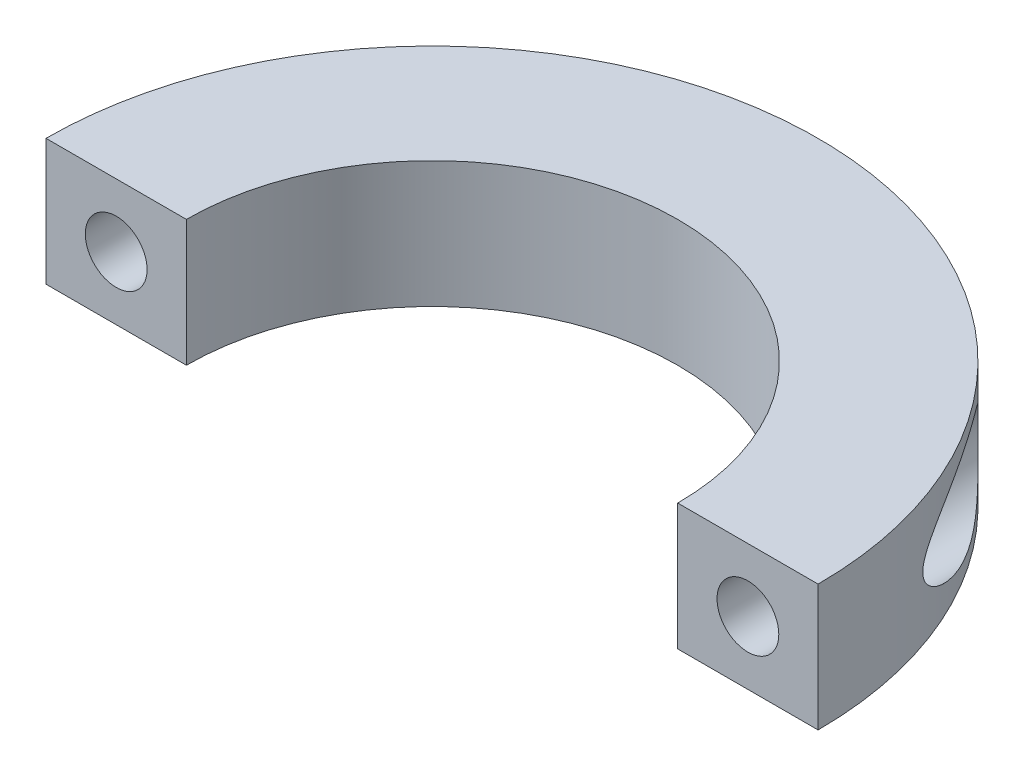
from build123d import *

# Parameters (mm, degrees)
BOSS_EXTRUDE1_DEPTH        = 4.5
BOSS_EXTRUDE1_DEPTH_BACK   = 4.5
F_4_4_4_4_DIAMETER_HOLE1_D = 4.4
CUT_EXTRUDE1_START         = -8
SKETCH7_R                  = 3.5
CUT_EXTRUDE1_DEPTH         = 18


with BuildPart() as part:
    # Sketch1 → Boss-Extrude1 (new, two sides: drawn at the far end of the back side and taken through both)
    with BuildSketch(Plane(origin=(0, 0, 0), x_dir=(1, 0, 0), z_dir=(0, 1, 0)).offset(-BOSS_EXTRUDE1_DEPTH_BACK)):
        with BuildLine():
            Line((-27.5, 0), (-17.5, 0))
            ThreePointArc((-17.5, 0), (0, 17.5), (17.5, 0))
            Line((17.5, 0), (27.5, 0))
            ThreePointArc((27.5, 0), (0, 27.5), (-27.5, 0))
        make_face()
    extrude(amount=BOSS_EXTRUDE1_DEPTH + BOSS_EXTRUDE1_DEPTH_BACK)

    # Ø4.4 (4.4) Diameter Hole1 (through all)
    with Locations(Plane(origin=(22.5, 0, 0), x_dir=(1, 0, 0), z_dir=(0, 0, 1))):
        with Locations((0, 0), (-45, 0)):
            Hole(F_4_4_4_4_DIAMETER_HOLE1_D / 2)

    # Sketch7 → Cut-Extrude1 (cut)
    with BuildSketch(Plane.XY.offset(CUT_EXTRUDE1_START)):
        with Locations((-22.5, 0)):
            Circle(SKETCH7_R)
        with Locations((22.5, 0)):
            Circle(SKETCH7_R)
    extrude(amount=-CUT_EXTRUDE1_DEPTH, mode=Mode.SUBTRACT)


solid = part.part
